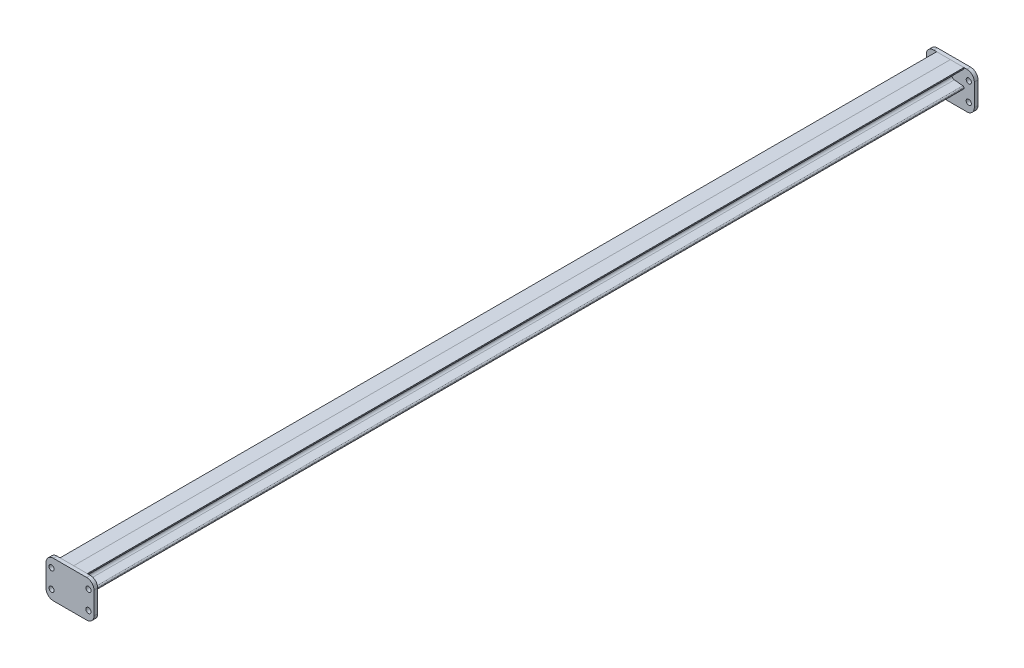
from build123d import *

# Parameters (mm, degrees)
MEMBER_5_1_DEPTH    = 2374
MEMBER_5_2_DEPTH    = 2374
EXTRUDE_1_DEPTH     = 10
SKETCH_15_R         = 7
CUT_EXTRUDE_1_DEPTH = 10
EXTRUDE_2_DEPTH     = 10
SKETCH_17_R         = 7
CUT_EXTRUDE_2_DEPTH = 10


with BuildPart() as part:
    # 草图12 → Member 5_1 (new body)
    with BuildSketch(Plane(origin=(0, 0, 0), x_dir=(1, 0, 0), z_dir=(0, 0, -1))):
        with BuildLine():
            Line((0, -25), (37, -25))
            Line((37, -25), (37, -22.792319516))
            ThreePointArc((37, -22.792319516), (36.095071711, -20.443787461), (33.848226964, -19.309685745))
            Line((33.848226964, -19.309685745), (10.803546073, -17.005458605))
            ThreePointArc((10.803546073, -17.005458605), (6.309856578, -14.737255173), (4.5, -10.040191063))
            Line((4.5, -10.040191063), (4.5, 10.040191063))
            ThreePointArc((4.5, 10.040191063), (6.309856578, 14.737255173), (10.803546073, 17.005458605))
            Line((10.803546073, 17.005458605), (33.848226964, 19.309685745))
            ThreePointArc((33.848226964, 19.309685745), (36.095071711, 20.443787461), (37, 22.792319516))
            Line((37, 22.792319516), (37, 25))
            Line((37, 25), (0, 25))
            Line((0, 25), (0, -25))
        make_face()
    extrude(amount=MEMBER_5_1_DEPTH)


with BuildPart() as body_2:
    # 草图13 → Member 5_2 (new body)
    with BuildSketch(Plane(origin=(0, 0, 0), x_dir=(-1, 0, 0), z_dir=(0, 0, -1))):
        with BuildLine():
            Line((0, -25), (37, -25))
            Line((37, -25), (37, -22.792319516))
            ThreePointArc((37, -22.792319516), (36.095071711, -20.443787461), (33.848226964, -19.309685745))
            Line((33.848226964, -19.309685745), (10.803546073, -17.005458605))
            ThreePointArc((10.803546073, -17.005458605), (6.309856578, -14.737255173), (4.5, -10.040191063))
            Line((4.5, -10.040191063), (4.5, 10.040191063))
            ThreePointArc((4.5, 10.040191063), (6.309856578, 14.737255173), (10.803546073, 17.005458605))
            Line((10.803546073, 17.005458605), (33.848226964, 19.309685745))
            ThreePointArc((33.848226964, 19.309685745), (36.095071711, 20.443787461), (37, 22.792319516))
            Line((37, 22.792319516), (37, 25))
            Line((37, 25), (0, 25))
            Line((0, 25), (0, -25))
        make_face()
    extrude(amount=MEMBER_5_2_DEPTH)


with BuildPart() as body_3:
    # 草图14 → 凸台-拉伸1 (new body)
    with BuildSketch(Plane.XY):
        with BuildLine():
            Line((45, 25), (-45, 25))
            ThreePointArc((-45, 25), (-59.142135624, 19.142135624), (-65, 5))
            Line((-65, 5), (-65, -55))
            ThreePointArc((-65, -55), (-59.142135624, -69.142135624), (-45, -75))
            Line((-45, -75), (45, -75))
            ThreePointArc((45, -75), (59.142135624, -69.142135624), (65, -55))
            Line((65, -55), (65, 5))
            ThreePointArc((65, 5), (59.142135624, 19.142135624), (45, 25))
        make_face()
    extrude(amount=EXTRUDE_1_DEPTH)

    # 草图15 → 切除-拉伸1 (cut)
    with BuildSketch(Plane.XY.offset(10)):
        with Locations((-50, 0)):
            Circle(SKETCH_15_R)
        with Locations((-50, -50)):
            Circle(SKETCH_15_R)
        with Locations((50, 0)):
            Circle(SKETCH_15_R)
        with Locations((50, -50)):
            Circle(SKETCH_15_R)
    extrude(amount=-CUT_EXTRUDE_1_DEPTH, mode=Mode.SUBTRACT)


with BuildPart() as body_4:
    # 草图16 → 凸台-拉伸2 (new body)
    with BuildSketch(Plane(origin=(0, 0, -2374), x_dir=(-1, 0, 0), z_dir=(0, 0, -1))):
        with BuildLine():
            Line((-65, 5), (-65, -55))
            ThreePointArc((-65, -55), (-59.142135624, -69.142135624), (-45, -75))
            Line((-45, -75), (45, -75))
            ThreePointArc((45, -75), (59.142135624, -69.142135624), (65, -55))
            Line((65, -55), (65, 5))
            ThreePointArc((65, 5), (59.142135624, 19.142135624), (45, 25))
            Line((45, 25), (-45, 25))
            ThreePointArc((-45, 25), (-59.142135624, 19.142135624), (-65, 5))
        make_face()
    extrude(amount=EXTRUDE_2_DEPTH)

    # 草图17 → 切除-拉伸2 (cut)
    with BuildSketch(Plane(origin=(0, 0, -2384), x_dir=(-1, 0, 0), z_dir=(0, 0, -1))):
        with Locations((50, 0)):
            Circle(SKETCH_17_R)
        with Locations((50, -50)):
            Circle(SKETCH_17_R)
        with Locations((-50, -50)):
            Circle(SKETCH_17_R)
        with Locations((-50, 0)):
            Circle(SKETCH_17_R)
    extrude(amount=-CUT_EXTRUDE_2_DEPTH, mode=Mode.SUBTRACT)


solid = Compound([part.part, body_2.part, body_3.part, body_4.part])
